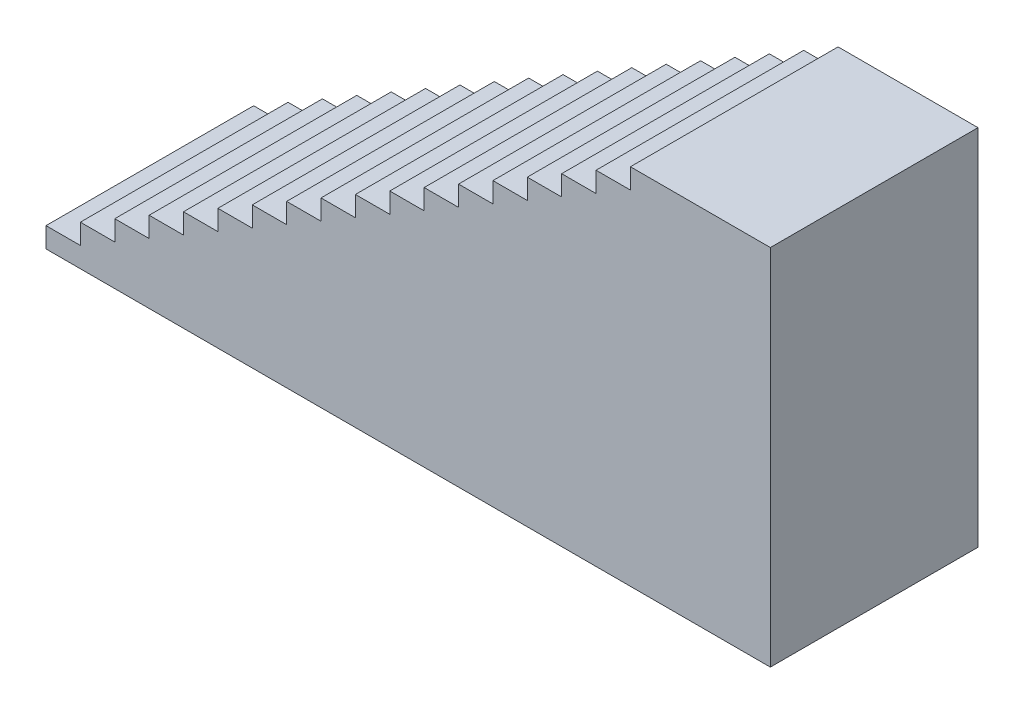
from build123d import *

# Parameters (mm, degrees)
SKETCH1_W           = 1670.558
SKETCH1_H           = 800.1
BOSS_EXTRUDE1_DEPTH = 457.2
CUT_EXTRUDE1_DEPTH  = 457.2


with BuildPart() as part:
    # Sketch1 → Boss-Extrude1 (new body)
    with BuildSketch(Plane.XY):
        with Locations((-20.24385353, 108.686840885)):
            Rectangle(SKETCH1_W, SKETCH1_H)
    extrude(amount=BOSS_EXTRUDE1_DEPTH)

    # Sketch2 → Cut-Extrude1 (cut)
    with BuildSketch(Plane.XY.offset(457.2)):
        Polygon((506.93314647, 508.736840885), (506.93314647, 464.286840885), (431.24114647, 464.286840885), (431.24114647, 419.836840885), (355.54914647, 419.836840885), (355.54914647, 375.386840885), (279.85714647, 375.386840885), (279.85714647, 330.936840885), (204.16514647, 330.936840885), (204.16514647, 286.486840885), (128.47314647, 286.486840885), (128.47314647, 242.036840885), (52.78114647, 242.036840885), (52.78114647, 197.586840885), (-22.91085353, 197.586840885), (-22.91085353, 153.136840885), (-98.60285353, 153.136840885), (-98.60285353, 108.686840885), (-174.29485353, 108.686840885), (-174.29485353, 64.236840885), (-249.98685353, 64.236840885), (-249.98685353, 19.786840885), (-325.67885353, 19.786840885), (-325.67885353, -24.663159115), (-401.37085353, -24.663159115), (-401.37085353, -69.113159115), (-477.06285353, -69.113159115), (-477.06285353, -113.563159115), (-552.75485353, -113.563159115), (-552.75485353, -158.013159115), (-628.44685353, -158.013159115), (-628.44685353, -202.463159115), (-704.13885353, -202.463159115), (-704.13885353, -246.913159115), (-779.83085353, -246.913159115), (-779.83085353, -291.363159115), (-855.52285353, -291.363159115), (-855.52285353, 508.736840885), align=None)
    extrude(amount=-CUT_EXTRUDE1_DEPTH, mode=Mode.SUBTRACT)


solid = part.part
